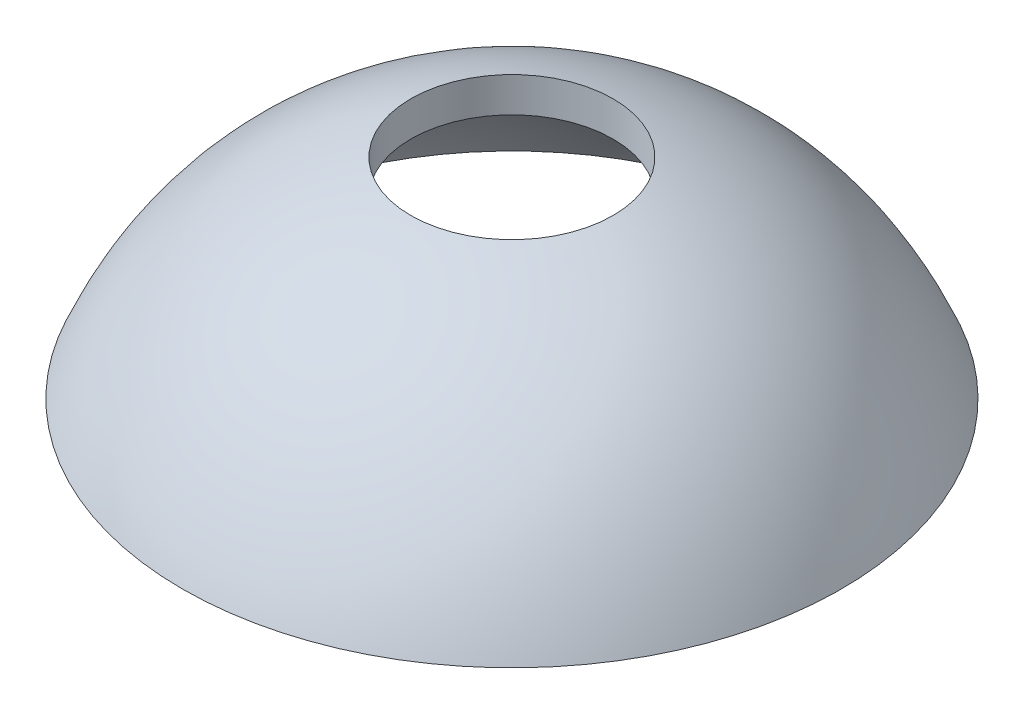
from build123d import *


with BuildPart() as part:
    # Sketch1 → Revolve1 (revolve)
    with BuildSketch(Plane.XY):
        with BuildLine():
            Line((7.366, 15.24), (7.366, 12.7))
            add(Edge.make_bspline(
                [(7.366, 12.7), (17.570694572, 9.699654506), (22.098, 0)],
                knots=[0, 0, 0, 1, 1, 1], degree=2))
            Line((22.098, 0), (24.003, 0))
            add(Edge.make_bspline(
                [(7.366, 15.24), (19.158945818, 11.756358265), (24.003, 0)],
                knots=[0, 0, 0, 1, 1, 1], degree=2))
        make_face()
    revolve(axis=Axis((0, 63.149773353, 0), (0, -1, 0)))


solid = part.part
